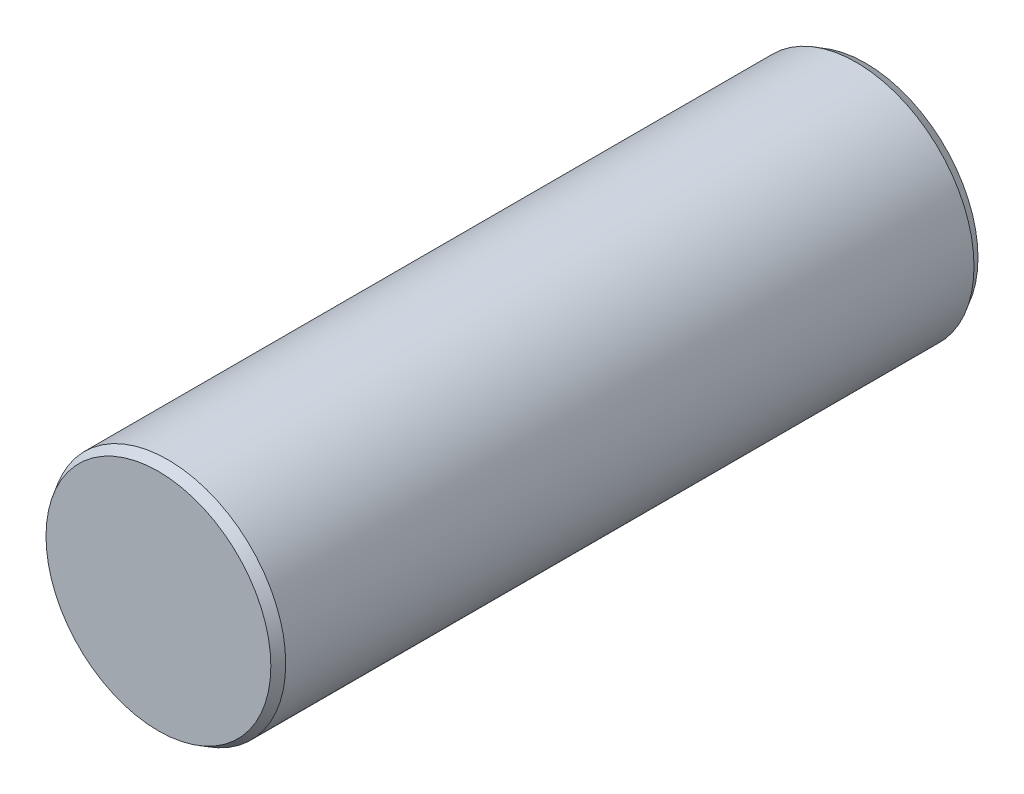
from build123d import *

# Parameters (mm, degrees)
ESQUISSE1_R        = 2.5
BOSS_EXTRU_1_DEPTH = 7.5
CHANFREIN1_SIZE    = 0.2
CHANFREIN1_SIZE2   = 0.115470054


with BuildPart() as part:
    # Esquisse1 → Boss.-Extru.1 (new body, symmetric)
    with BuildSketch(Plane.XY):
        Circle(ESQUISSE1_R)
    extrude(amount=BOSS_EXTRU_1_DEPTH, both=True)

    # Chanfrein1
    chanfrein1_edges = [part.edges().sort_by_distance(p)[0] for p in [
        (-2.5, 0, -7.5),
        (-2.5, 0, 7.5),
    ]]
    chanfrein1_side = [part.faces().sort_by_distance(p)[0] for p in [
        (-2.5, 0, 0),
    ]]
    chamfer(chanfrein1_edges, length=CHANFREIN1_SIZE, length2=CHANFREIN1_SIZE2, reference=chanfrein1_side[0])


solid = part.part
